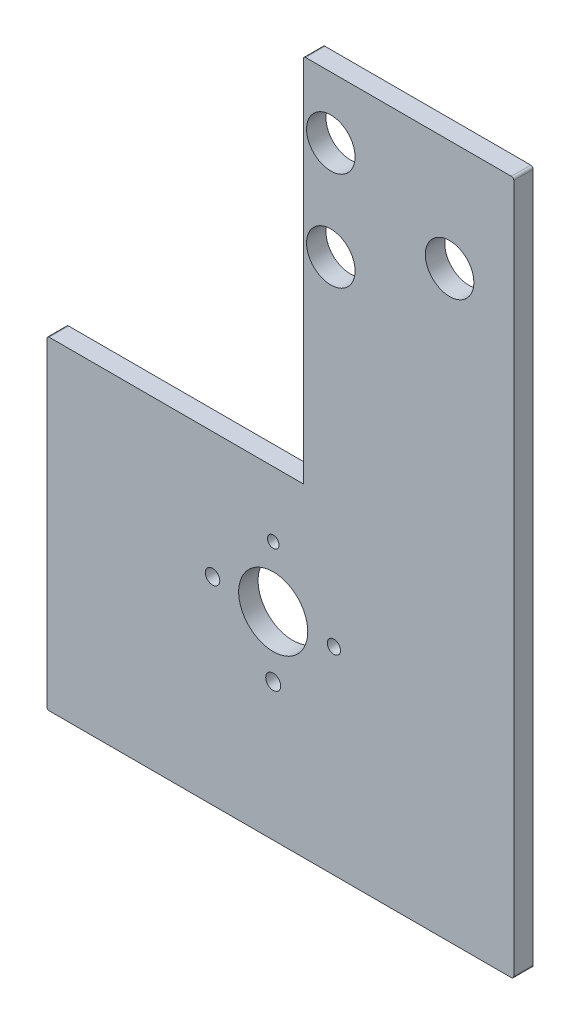
from build123d import *

# Parameters (mm, degrees)
SKETCH_1_R          = 10
SKETCH_1_R_2        = 14.237670301
EXTRUDE_1_DEPTH     = 8
SKETCH_2_R          = 2.388792686
SKETCH_2_R_2        = 2.719652574
SKETCH_2_R_3        = 3.086328998
SKETCH_2_R_4        = 2.978260763
CUT_EXTRUDE_1_DEPTH = 9


with BuildPart() as part:
    # 草图1 → 凸台-拉伸1 (new body)
    with BuildSketch(Plane.XY):
        with BuildLine():
            Line((4236.361201479, 3653.279497209), (4045.920724491, 3653.279497209))
            ThreePointArc((4045.920724491, 3653.279497209), (4045.21361771, 3653.572390428), (4044.920724491, 3654.279497209))
            Line((4044.920724491, 3654.279497209), (4044.920724491, 3785.62643227))
            ThreePointArc((4044.920724491, 3785.62643227), (4045.21361771, 3786.333539051), (4045.920724491, 3786.62643227))
            Line((4045.920724491, 3786.62643227), (4150.606085218, 3786.62643227))
            Line((4150.606085218, 3786.62643227), (4150.606085218, 3938.288234625))
            ThreePointArc((4150.606085218, 3938.288234625), (4150.898978436, 3938.995341406), (4151.606085218, 3939.288234625))
            Line((4151.606085218, 3939.288234625), (4236.361201479, 3939.288234625))
            ThreePointArc((4236.361201479, 3939.288234625), (4237.06830826, 3938.995341406), (4237.361201479, 3938.288234625))
            Line((4237.361201479, 3938.288234625), (4237.361201479, 3654.279497209))
            ThreePointArc((4237.361201479, 3654.279497209), (4237.06830826, 3653.572390428), (4236.361201479, 3653.279497209))
        make_face()
        with Locations((4210.911253899, 3893.629242063)):
            Circle(SKETCH_1_R, mode=Mode.SUBTRACT)
        with Locations((4161.960456262, 3913.970224185)):
            Circle(SKETCH_1_R, mode=Mode.SUBTRACT)
        with Locations((4161.960456262, 3873.288259941)):
            Circle(SKETCH_1_R, mode=Mode.SUBTRACT)
        with Locations((4138.223317867, 3734.818667022)):
            Circle(SKETCH_1_R_2, mode=Mode.SUBTRACT)
    extrude(amount=EXTRUDE_1_DEPTH)

    # 草图2 → 切除-拉伸1 (cut, through all)
    with BuildSketch(Plane.XY.offset(8)):
        with Locations((4138.223317867, 3759.818667022)):
            Circle(SKETCH_2_R)
        with Locations((4163.223317867, 3734.818667022)):
            Circle(SKETCH_2_R_2)
        with Locations((4138.223317867, 3709.818667022)):
            Circle(SKETCH_2_R_3)
        with Locations((4113.223317867, 3734.818667022)):
            Circle(SKETCH_2_R_4)
    extrude(amount=-CUT_EXTRUDE_1_DEPTH, mode=Mode.SUBTRACT)


solid = part.part
